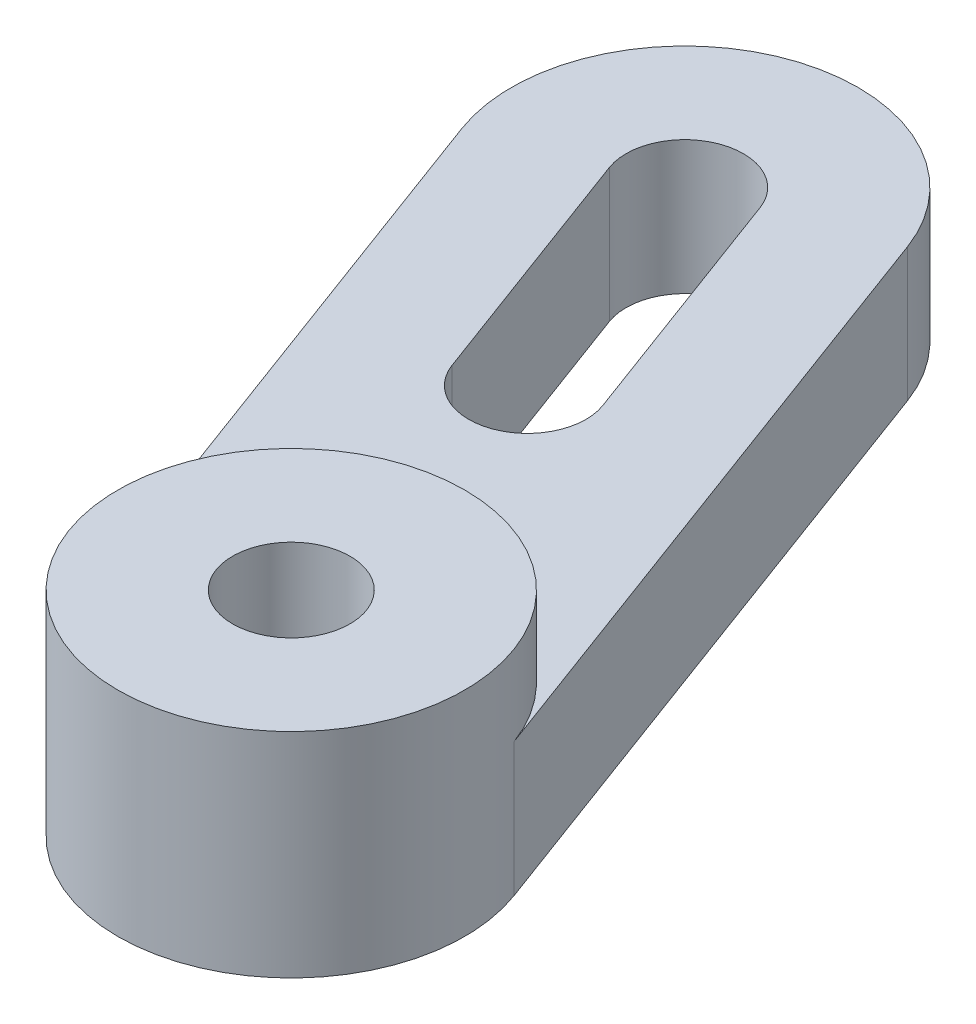
from build123d import *

# Parameters (mm, degrees)
SKETCH1_R           = 2.2
BOSS_EXTRUDE1_DEPTH = 5
SKETCH2_R           = 6.5
SKETCH2_R_2         = 2.2
BOSS_EXTRUDE2_DEPTH = 3


with BuildPart() as part:
    # Sketch1 → Boss-Extrude1 (new body)
    with BuildSketch(Plane(origin=(0, 0, 0), x_dir=(1, 0, 0), z_dir=(0, 1, 0))):
        with BuildLine():
            Line((-13.158208581, -1.850148868), (-21.850124899, 21.590213559))
            ThreePointArc((-21.850124899, 21.590213559), (-18.015528911, 29.944606033), (-9.661136437, 26.110010045))
            Line((-9.661136437, 26.110010045), (-0.969220119, 2.669647618))
            ThreePointArc((-0.969220119, 2.669647618), (-4.803816107, -5.684744856), (-13.158208581, -1.850148868))
        make_face()
        with Locations(Location((-7.06371435, 0.409749375, 0), (0, 0, 270))):  # turned: the seam where the file's is
            Circle(SKETCH1_R, mode=Mode.SUBTRACT)
        with BuildLine():
            Line((-13.692878775, 24.615000438), (-10.216112247, 15.238855467))
            ThreePointArc((-10.216112247, 15.238855467), (-11.513975505, 12.411214938), (-14.341616034, 13.709078195))
            Line((-14.341616034, 13.709078195), (-17.818382562, 23.085223166))
            ThreePointArc((-17.818382562, 23.085223166), (-16.520519304, 25.912863695), (-13.692878775, 24.615000438))
        make_face(mode=Mode.SUBTRACT)
    extrude(amount=BOSS_EXTRUDE1_DEPTH)

    # Sketch2 → Boss-Extrude2 (add)
    with BuildSketch(Plane(origin=(0, 5, 0), x_dir=(-1, 0, 0), z_dir=(0, 1, 0))):
        with Locations(Location((7.06371435, -0.409749375, 0), (0, 0, 200.345274498))):  # turned: the seam where the file's is
            Circle(SKETCH2_R)
        with Locations(Location((7.06371435, -0.409749375, 0), (0, 0, 90))):  # turned: the seam where the file's is
            Circle(SKETCH2_R_2, mode=Mode.SUBTRACT)
    extrude(amount=BOSS_EXTRUDE2_DEPTH)


solid = part.part
